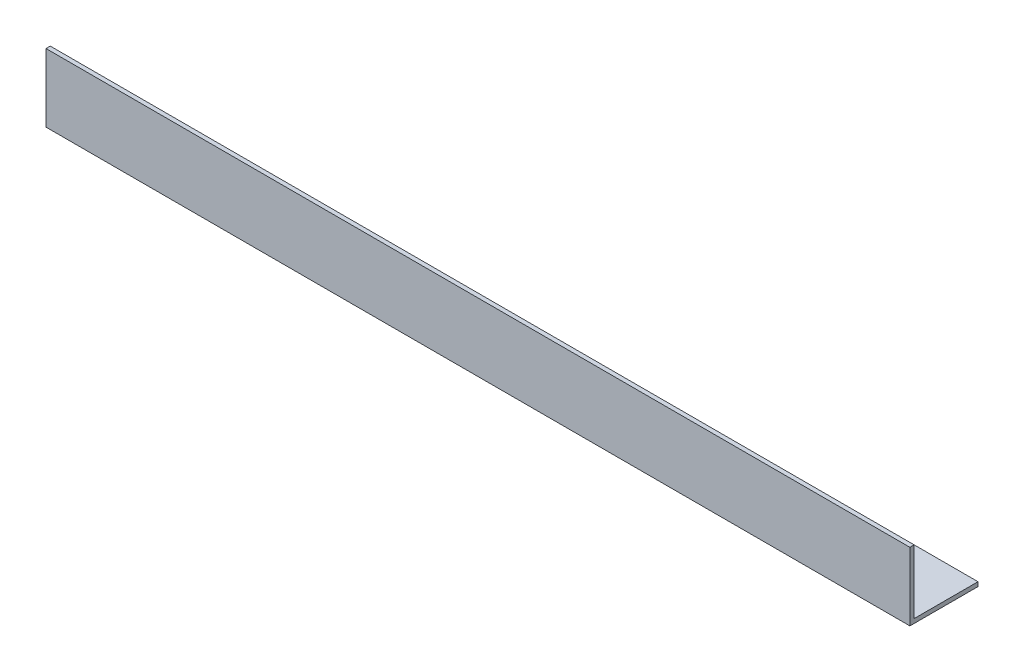
from build123d import *

# Parameters (mm, degrees)
SALIENTE_EXTRUIR1_DEPTH = 203


with BuildPart() as part:
    # Croquis1 → Saliente-Extruir1 (new body)
    with BuildSketch(Plane(origin=(0, 0, 0), x_dir=(0, 0, -1), z_dir=(1, 0, 0))):
        Polygon((0, 16), (0, 0), (16, 0), (16, 1), (1, 1), (1, 16), align=None)
    extrude(amount=SALIENTE_EXTRUIR1_DEPTH)


solid = part.part
